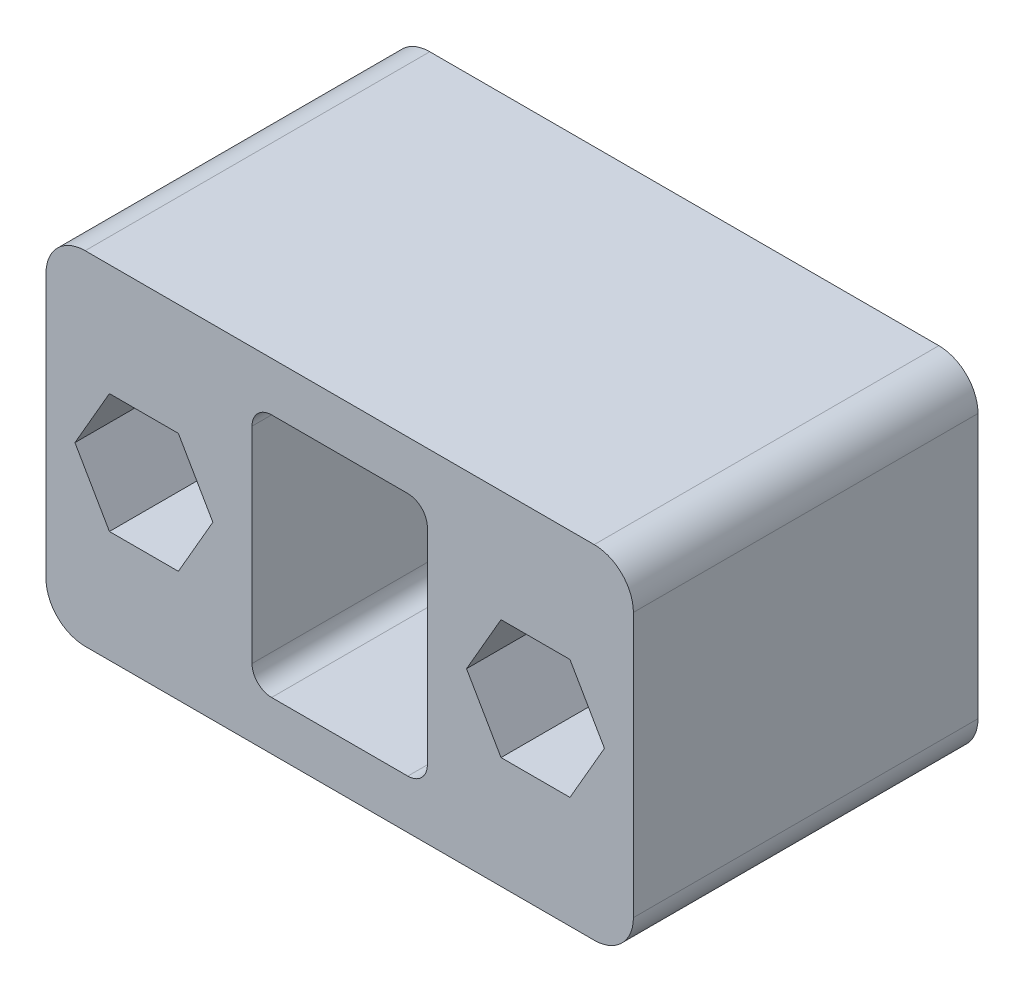
from build123d import *

# Parameters (mm, degrees)
SKETCH_1_W          = 30
SKETCH_1_H          = 17.5
SKETCH_1_W_2        = 8.956326716
SKETCH_1_H_2        = 12.5
EXTRUDE_1_DEPTH     = 17.6
FILLET_1_R          = 1
SKETCH_3_W          = 10.521836642
SKETCH_3_H          = 17.5
EXTRUDE_2_DEPTH     = 2.1
FILLET_2_R          = 2
SKETCH_4_R          = 2.1
CUT_EXTRUDE_1_DEPTH = 10


with BuildPart() as part:
    # 草图1 → 凸台-拉伸1 (new body)
    with BuildSketch(Plane.XY):
        Rectangle(SKETCH_1_W, SKETCH_1_H)
        Polygon((11.760918321, 3.05), (8.239081679, 3.05), (6.478163358, 0), (8.239081679, -3.05), (11.760918321, -3.05), (13.521836642, 0), align=None, mode=Mode.SUBTRACT)
        Polygon((-11.760918321, 3.05), (-13.521836642, 0), (-11.760918321, -3.05), (-8.239081679, -3.05), (-6.478163358, 0), (-8.239081679, 3.05), align=None, mode=Mode.SUBTRACT)
        Rectangle(SKETCH_1_W_2, SKETCH_1_H_2, mode=Mode.SUBTRACT)
    extrude(amount=EXTRUDE_1_DEPTH)

    # 圆角1
    fillet_1_edges = [part.edges().sort_by_distance(p)[0] for p in [
        (4.478163358, -6.25, 8.8),
        (4.478163358, 6.25, 8.8),
        (-4.478163358, 6.25, 8.8),
        (-4.478163358, -6.25, 8.8),
    ]]
    fillet(fillet_1_edges, radius=FILLET_1_R)

    # 草图3 → 凸台-拉伸2 (add)
    with BuildSketch(Plane(origin=(0, 0, 0), x_dir=(-1, 0, 0), z_dir=(0, 0, -1))):
        with Locations((-9.739081679, 0)):
            Rectangle(SKETCH_3_W, SKETCH_3_H)
        with Locations((9.739081679, 0)):
            Rectangle(SKETCH_3_W, SKETCH_3_H)
    extrude(amount=-EXTRUDE_2_DEPTH)

    # 圆角2
    fillet_2_edges = [part.edges().sort_by_distance(p)[0] for p in [
        (15, -8.75, 8.8),
        (-15, -8.75, 8.8),
        (-15, 8.75, 8.8),
        (15, 8.75, 8.8),
    ]]
    fillet(fillet_2_edges, radius=FILLET_2_R)

    # 草图4 → 切除-拉伸1 (cut)
    with BuildSketch(Plane.XY.offset(2.1)):
        with Locations((10, 0)):
            Circle(SKETCH_4_R)
        with Locations((-10, 0)):
            Circle(SKETCH_4_R)
    extrude(amount=-CUT_EXTRUDE_1_DEPTH, mode=Mode.SUBTRACT)


solid = part.part
